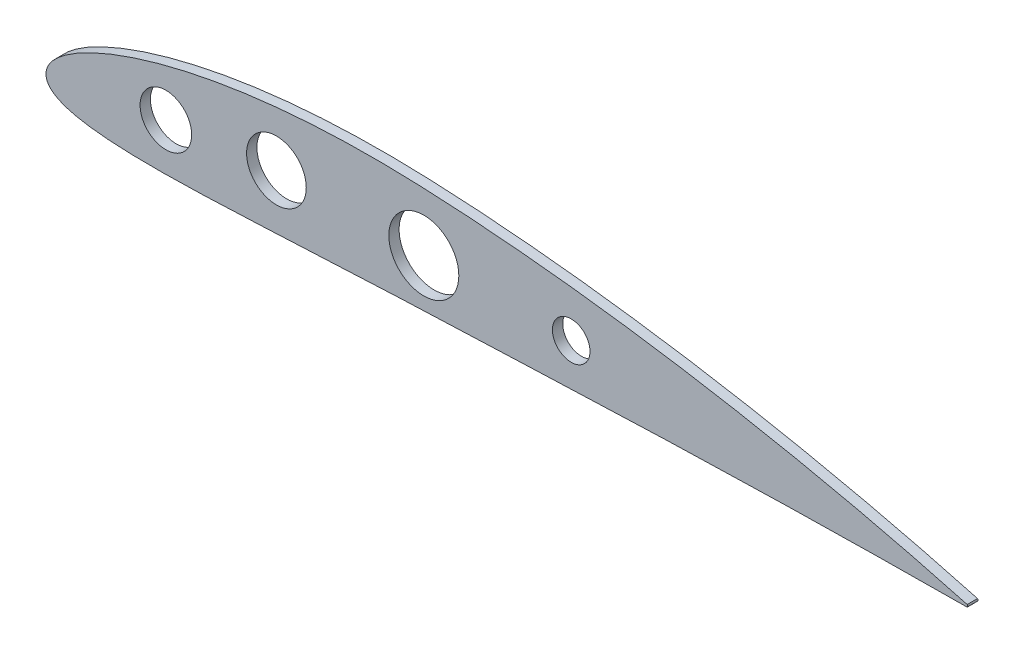
from build123d import *

# Parameters (mm, degrees)
SKETCH_1_R      = 8.1
SKETCH_1_R_2    = 5.1
SKETCH_1_R_3    = 7
SKETCH_1_R_4    = 9.5
EXTRUDE_1_DEPTH = 1.4


with BuildPart() as part:
    # Эскиз1 → Бобышка-Вытянуть1 (new body, symmetric)
    with BuildSketch(Plane.XY):
        with BuildLine():
            ThreePointArc((250, 0.315), (250.130477272, 0), (250, -0.315))
            add(Edge.make_bspline(
                [(0.047975, 0.621425), (0.02271382, 0.373490086), (-0.027820789, -0.122499975), (0.077991212, -0.88443459), (0.34969565, -1.63883807), (0.814331135, -2.365068924), (1.46348078, -3.039275245), (2.290973017, -3.66099947), (3.30592875, -4.235779621), (4.535255619, -4.773674144), (6.029745688, -5.282192165), (7.868981215, -5.765316676), (10.168831392, -6.221716593), (13.075438189, -6.639618731), (16.728115363, -6.992956738), (21.189952096, -7.247345145), (26.399984416, -7.376638849), (32.197398564, -7.376256913), (38.397806759, -7.26143658), (44.857621768, -7.056641358), (51.486543096, -6.786453532), (58.230980932, -6.472324587), (65.052094606, -6.132852265), (71.910772709, -5.784005177), (78.771375576, -5.439680454), (85.61049861, -5.110951253), (92.43210759, -4.804953326), (99.25503119, -4.531981655), (106.097378405, -4.278274671), (112.96921168, -4.003089926), (119.864404255, -3.723176184), (126.773860473, -3.440067296), (133.681563213, -3.1586956), (140.581870407, -2.88238072), (147.472013762, -2.613922958), (154.352602411, -2.355626415), (161.225044134, -2.109369921), (168.090869746, -1.876634074), (174.951578522, -1.658643104), (181.808595966, -1.456378123), (188.663234462, -1.270383377), (195.516645168, -1.101112884), (202.369532894, -0.948617189), (211.49919029, -0.767742353), (220.603098666, -0.619939742), (229.617630172, -0.50292618), (236.087353854, -0.431514192), (241.980776913, -0.376520461), (246.558970011, -0.339535886), (249.120490965, -0.321271242), (250, -0.315)],
                knots=[0, 0, 0, 0, 0.002941446, 0.005884319, 0.00901613, 0.012364547, 0.016007934, 0.020036845, 0.024573728, 0.029783835, 0.03589701, 0.04324044, 0.052275965, 0.063634589, 0.077983176, 0.095698161, 0.116520086, 0.13966073, 0.16431217, 0.18991889, 0.216157201, 0.242837762, 0.269833583, 0.296993022, 0.324123272, 0.351139107, 0.378035509, 0.404946016, 0.431960837, 0.459078395, 0.4863474, 0.51364083, 0.540928595, 0.568176028, 0.595379569, 0.622543445, 0.64967326, 0.676775201, 0.703855228, 0.730918775, 0.757971338, 0.785017763, 0.812061651, 0.839103366, 0.893099152, 0.919831065, 0.945809917, 0.969680601, 0.989589706, 1, 1, 1, 1], degree=3))
            add(Edge.make_bspline(
                [(250, 0.315), (249.15566774, 0.545019818), (246.720175698, 1.208516243), (242.391332083, 2.358339053), (236.849761204, 3.787625364), (230.779918279, 5.298008837), (224.455917947, 6.812866028), (218.030543496, 8.291610632), (211.562405045, 9.719735057), (205.072411509, 11.092374932), (198.567970913, 12.407850726), (192.052369914, 13.665297924), (185.527619973, 14.864093303), (178.995338991, 16.003404779), (172.457064741, 17.082388115), (165.914317095, 18.099827841), (159.368680729, 19.054501815), (152.821805128, 19.944885603), (146.275439401, 20.769282183), (139.731359791, 21.525676113), (133.19183673, 22.212004249), (126.658683026, 22.825721429), (120.136770918, 23.363973266), (113.628567141, 23.824677324), (107.152732037, 24.200242594), (100.741095693, 24.49839951), (94.411752715, 24.686649768), (88.155917993, 24.74009565), (81.949043055, 24.658849144), (75.780520592, 24.441013808), (69.653692942, 24.081884821), (63.575410502, 23.578006361), (57.555189551, 22.924946658), (51.605762688, 22.119065522), (45.744400311, 21.156564432), (39.995857594, 20.03537139), (34.397919842, 18.756316234), (29.010382104, 17.327615608), (23.925798408, 15.771864921), (19.27067884, 14.134269434), (15.179098391, 12.483335438), (11.74047579, 10.895610995), (8.959371869, 9.429577365), (6.76089118, 8.108603199), (5.033709748, 6.924638055), (3.671694933, 5.854229664), (2.592101123, 4.871305369), (1.738175669, 3.952595743), (1.06987083, 3.080946373), (0.57164541, 2.241622102), (0.215773899, 1.430785397), (0.102255582, 0.883241695), (0.047975, 0.621425)],
                knots=[0, 0, 0, 0, 0.0101622, 0.029313053, 0.052011605, 0.076619468, 0.101948061, 0.127526132, 0.153184131, 0.178867888, 0.204557903, 0.230245712, 0.255925967, 0.281594302, 0.30724642, 0.332878042, 0.358484538, 0.384061186, 0.409602822, 0.435103874, 0.460559416, 0.485959195, 0.51130307, 0.536551515, 0.561723366, 0.586628867, 0.611085431, 0.6352512, 0.659272176, 0.683163753, 0.706922144, 0.73053591, 0.7539832, 0.77723469, 0.800246382, 0.822950709, 0.845237155, 0.866915896, 0.887662335, 0.906968281, 0.924203157, 0.938878975, 0.950931611, 0.960693484, 0.968646729, 0.975232933, 0.980794744, 0.985583761, 0.989781539, 0.993521313, 0.996902113, 1, 1, 1, 1], degree=3))
        make_face()
        with Locations((62.532619318, 8.596197208)):
            Circle(SKETCH_1_R, mode=Mode.SUBTRACT)
        with Locations((142.532619318, 8.596197208)):
            Circle(SKETCH_1_R_2, mode=Mode.SUBTRACT)
        with Locations((32.532619318, 5.448144701)):
            Circle(SKETCH_1_R_3, mode=Mode.SUBTRACT)
        with Locations((102.532619318, 8.596197208)):
            Circle(SKETCH_1_R_4, mode=Mode.SUBTRACT)
    extrude(amount=EXTRUDE_1_DEPTH, both=True)


solid = part.part
